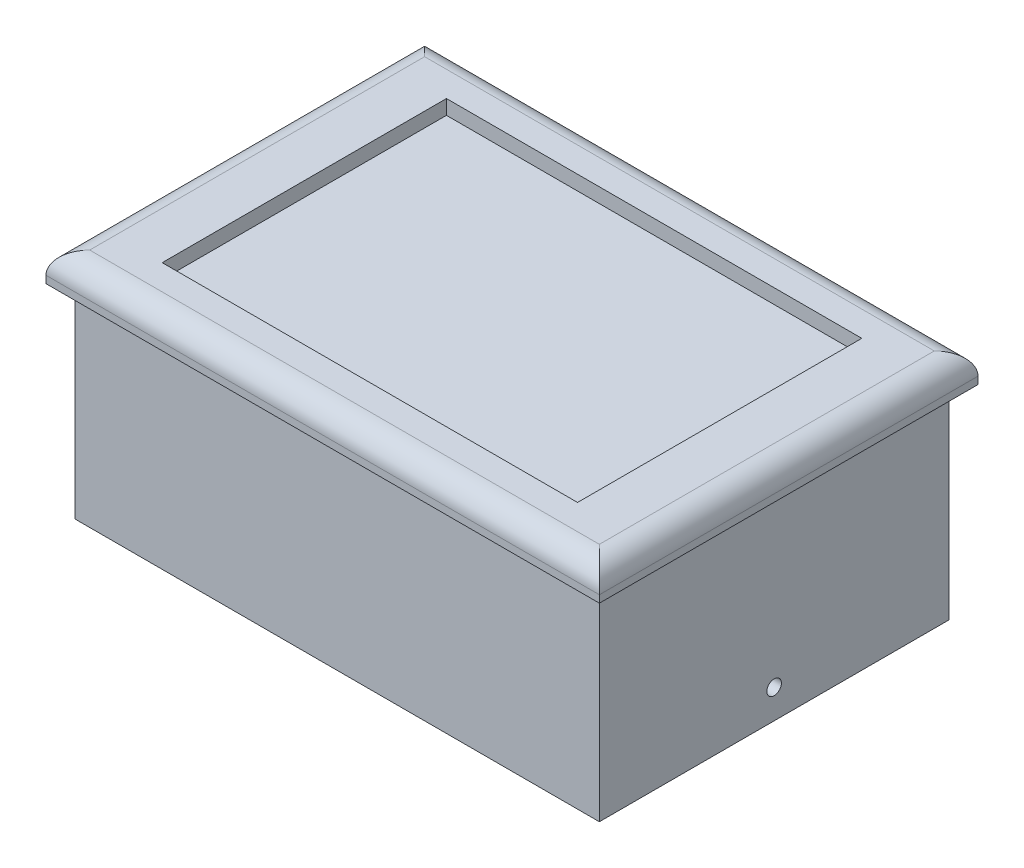
from build123d import *

# Parameters (mm, degrees)
SKETCH1_W                                 = 120.65
SKETCH1_H                                 = 82.55
MAINBODY_DEPTH                            = 50.8
SKETCH2_W                                 = 90.552524
SKETCH2_H                                 = 61.977524
SOLARPANELRECESS_DEPTH                    = 3.175
SKETCH3_W                                 = 77.852524
SKETCH3_H                                 = 49.277524
SOLARPANELWIRINGRECESS_DEPTH              = 88.240311067
SKETCH4_W                                 = 127
SKETCH4_H                                 = 88.9
SKETCH4_W_2                               = 120.65
SKETCH4_H_2                               = 82.55
SKETCH4_W_3                               = 114.3
SKETCH4_H_3                               = 76.2
SKETCH4_W_4                               = 104.775
SKETCH4_H_4                               = 66.675
SKETCH4_W_5                               = 77.852524
SKETCH4_H_5                               = 49.277524
INSIDEENCLOSURERECESS_OUTSIDEFLANGE_DEPTH = 44.45
TOPFANCYFILLET_R                          = 4.7625
CABLEACCESS_REACH                         = 136.479
SKETCH9_R                                 = 1.5875
TOPEDGEHOLES_DEPTH                        = 135.479148012
CORNERSTANDOFFS_DEPTH                     = 15.875
SKETCH11_R                                = 1.143
SCREWSTANDOFFHOLES_DEPTH                  = 6.35
SKETCH12_W                                = 111.125
SKETCH12_H                                = 73.025
SKETCH12_W_2                              = 107.95
SKETCH12_H_2                              = 69.85
WEATHERSEALRECESS_DEPTH                   = 3.175
SKETCH13_W                                = 90.552524
SKETCH13_H                                = 61.977524
BLANKINSERT_BETTERBRIDGING_DEPTH          = 0.125


with BuildPart() as part:
    # Sketch1 → MainBody (new body)
    with BuildSketch(Plane(origin=(0, 0, 0), x_dir=(1, 0, 0), z_dir=(0, 1, 0))):
        Rectangle(SKETCH1_W, SKETCH1_H)
    extrude(amount=MAINBODY_DEPTH)

    # Sketch2 → SolarPanelRecess (cut)
    with BuildSketch(Plane(origin=(0, 50.8, 0), x_dir=(1, 0, 0), z_dir=(0, 1, 0))):
        Rectangle(SKETCH2_W, SKETCH2_H)
    extrude(amount=-SOLARPANELRECESS_DEPTH, mode=Mode.SUBTRACT)

    # Sketch3 → SolarPanelWiringRecess (cut, through all)
    with BuildSketch(Plane(origin=(0, 47.625, 0), x_dir=(1, 0, 0), z_dir=(0, 1, 0))):
        Rectangle(SKETCH3_W, SKETCH3_H)
    extrude(amount=-SOLARPANELWIRINGRECESS_DEPTH, mode=Mode.SUBTRACT)

    # Sketch4 → InsideEnclosureRecess_OutsideFlange (cut)
    with BuildSketch(Plane.XZ):
        Rectangle(SKETCH4_W, SKETCH4_H)
        Rectangle(SKETCH4_W_2, SKETCH4_H_2, mode=Mode.SUBTRACT)
        Rectangle(SKETCH4_W_2, SKETCH4_H_2)
        Rectangle(SKETCH4_W_3, SKETCH4_H_3, mode=Mode.SUBTRACT)
        Rectangle(SKETCH4_W_4, SKETCH4_H_4)
        Rectangle(SKETCH4_W_5, SKETCH4_H_5, mode=Mode.SUBTRACT)
    extrude(amount=-INSIDEENCLOSURERECESS_OUTSIDEFLANGE_DEPTH, mode=Mode.SUBTRACT)

    # TopFancyFillet
    topfancyfillet_edges = [part.edges().sort_by_distance(p)[0] for p in [
        (-60.325, 50.8, 0),
        (0, 50.8, 41.275),
        (60.325, 50.8, 0),
        (0, 50.8, -41.275),
    ]]
    fillet(topfancyfillet_edges, radius=TOPFANCYFILLET_R)

    # Sketch6 → CableAccess (cut, up to next)
    with BuildSketch(Plane.ZY.offset(57.15), mode=Mode.PRIVATE) as cableaccess_sk1:
        Polygon((-14.2875, 24.60625), (14.2875, 24.60625), (26.9875, 24.60625), (26.9875, 11.90625), (-23.8125, 11.90625), (-23.8125, 24.60625), align=None)
    cableaccess_tool1 = extrude(cableaccess_sk1.sketch, amount=-CABLEACCESS_REACH, mode=Mode.PRIVATE) & part.part
    add(cableaccess_tool1.solids().sort_by_distance((-57.15, 18.25625, 1.5875))[0], mode=Mode.SUBTRACT)

    # Sketch9 → TopEdgeHoles (cut, through all)
    with BuildSketch(Plane(origin=(57.15, 0, 0), x_dir=(0, 0, -1), z_dir=(1, 0, 0))):
        with Locations((0, 6.35)):
            Circle(SKETCH9_R)
    extrude(amount=-TOPEDGEHOLES_DEPTH, mode=Mode.SUBTRACT)

    # Sketch10 → CornerStandoffs (add)
    with BuildSketch(Plane.XZ.offset(-44.45)):
        with BuildLine():
            Line((-42.8625, 33.3375), (-52.3875, 33.3375))
            Line((-52.3875, 33.3375), (-52.3875, 23.8125))
            ThreePointArc((-52.3875, 23.8125), (-45.652307909, 26.602307909), (-42.8625, 33.3375))
        make_face()
        with BuildLine():
            ThreePointArc((-42.8625, -33.3375), (-45.652307909, -26.602307909), (-52.3875, -23.8125))
            Line((-52.3875, -23.8125), (-52.3875, -33.3375))
            Line((-52.3875, -33.3375), (-42.8625, -33.3375))
        make_face()
        with BuildLine():
            Line((52.3875, 33.3375), (42.8625, 33.3375))
            ThreePointArc((42.8625, 33.3375), (45.652307909, 26.602307909), (52.3875, 23.8125))
            Line((52.3875, 23.8125), (52.3875, 33.3375))
        make_face()
        with BuildLine():
            ThreePointArc((52.3875, -23.8125), (45.652307909, -26.602307909), (42.8625, -33.3375))
            Line((42.8625, -33.3375), (52.3875, -33.3375))
            Line((52.3875, -33.3375), (52.3875, -23.8125))
        make_face()
    extrude(amount=CORNERSTANDOFFS_DEPTH)

    # Sketch11 → ScrewStandoffHoles (cut)
    with BuildSketch(Plane.XZ.offset(-28.575)):
        with Locations(Location((46.83125, -28.575, 0), (0, 0, 270))):
            Circle(SKETCH11_R)
        with Locations(Location((-46.83125, -28.575, 0), (0, 0, 270))):
            Circle(SKETCH11_R)
        with Locations(Location((-46.83125, 28.575, 0), (0, 0, 270))):
            Circle(SKETCH11_R)
        with Locations(Location((46.83125, 28.575, 0), (0, 0, 270))):
            Circle(SKETCH11_R)
    extrude(amount=-SCREWSTANDOFFHOLES_DEPTH, mode=Mode.SUBTRACT)

    # Sketch12 → WeatherSealRecess (cut)
    with BuildSketch(Plane.XZ):
        Rectangle(SKETCH12_W, SKETCH12_H)
        Rectangle(SKETCH12_W_2, SKETCH12_H_2, mode=Mode.SUBTRACT)
    extrude(amount=-WEATHERSEALRECESS_DEPTH, mode=Mode.SUBTRACT)

    # Sketch13 → BlankInsert_BetterBridging (add)
    with BuildSketch(Plane(origin=(0, 47.625, 0), x_dir=(1, 0, 0), z_dir=(0, 1, 0))):
        Rectangle(SKETCH13_W, SKETCH13_H)
    extrude(amount=-BLANKINSERT_BETTERBRIDGING_DEPTH)


solid = part.part
